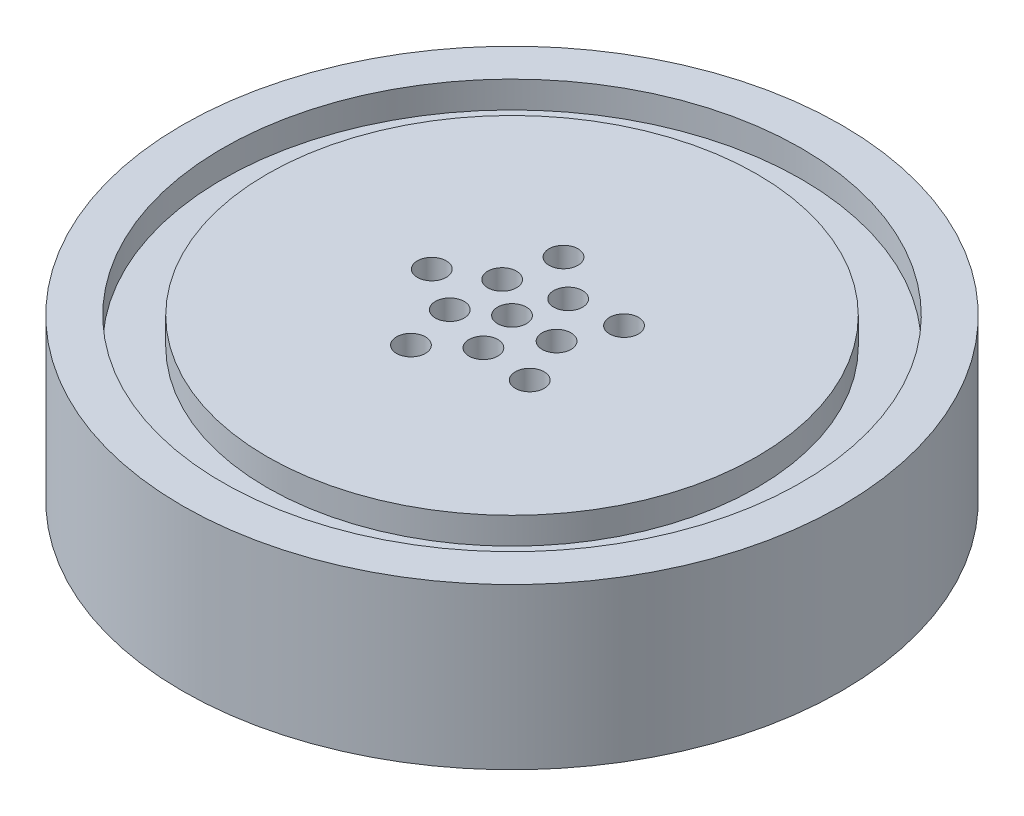
from build123d import *

# Parameters (mm, degrees)
SKETCH2_R                       = 23.495
BOSS_EXTRUDE1_DEPTH             = 11.43
SKETCH8_W                       = 3.175
SKETCH8_H                       = 1.905
SKETCH12_R                      = 9.525
BOSS_EXTRUDE2_DEPTH             = 6.35
F_46_0_081_DIAMETER_HOLE1_D     = 2.0574
F_46_0_081_DIAMETER_HOLE1_DEPTH = 17.78


with BuildPart() as part:
    # Sketch2 → Boss-Extrude1 (new body)
    with BuildSketch(Plane(origin=(0, 0, 0), x_dir=(1, 0, 0), z_dir=(0, 1, 0))):
        Circle(SKETCH2_R)
    extrude(amount=BOSS_EXTRUDE1_DEPTH)

    # Sketch8 → Cut-Revolve1 (revolve, cut)
    with BuildSketch(Plane.XY):
        with Locations((19.0373, 10.4775)):
            Rectangle(SKETCH8_W, SKETCH8_H)
    revolve(axis=Axis((0, -0.47625, 0), (0, 1, 0)), mode=Mode.SUBTRACT)

    # Sketch12 → Boss-Extrude2 (add)
    with BuildSketch(Plane.XZ):
        Circle(SKETCH12_R)
    extrude(amount=BOSS_EXTRUDE2_DEPTH)

    # #46 (0.081) Diameter Hole1
    with Locations(Plane(origin=(0, 11.43, 0), x_dir=(1, 0, 0), z_dir=(0, 1, 0))):
        with Locations((-5.715, 0), (-2.568628957, 1.866218176), (0, 0), (-1.766032123, 5.435287991), (4.623532123, 3.359192717), (4.623532123, -3.359192717), (-1.766032123, -5.435287991), (0.981128957, 3.019604439), (3.175, 0), (0.981128957, -3.019604439), (-2.568628957, -1.866218176)):
            Hole(F_46_0_081_DIAMETER_HOLE1_D / 2, depth=F_46_0_081_DIAMETER_HOLE1_DEPTH)


solid = part.part
